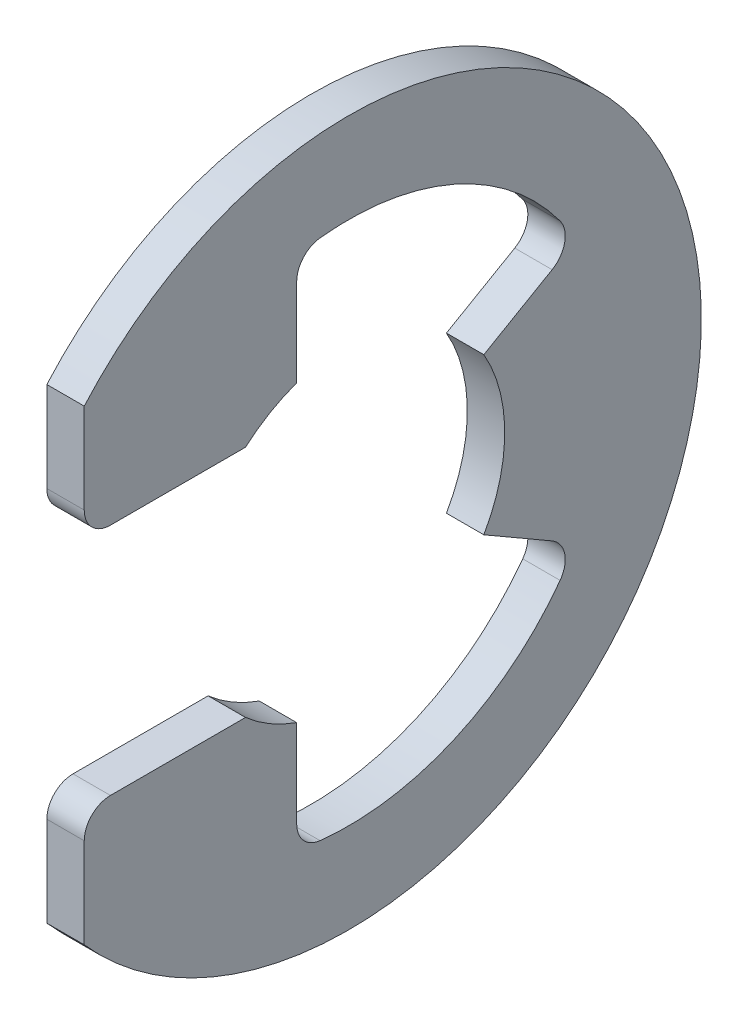
from build123d import *

# Parameters (mm, degrees)
EXTRUDE1_DEPTH = 0.4445
FILLET1_R      = 0.6223


with BuildPart() as part:
    # Sketch1 → Extrude1 (new body, symmetric)
    with BuildSketch(Plane(origin=(0, 0, 0), x_dir=(0, 0, -1), z_dir=(1, 0, 0))):
        with BuildLine():
            Line((-2.45287604, 2.7813), (-6.2865, 2.7813))
            Line((-6.2865, 2.7813), (-6.2865, 5.544171872))
            ThreePointArc((-6.2865, 5.544171872), (8.382, 0), (-6.2865, -5.544171872))
            Line((-6.2865, -5.544171872), (-6.2865, -2.7813))
            Line((-6.2865, -2.7813), (-2.45287604, -2.7813))
            ThreePointArc((-2.45287604, -2.7813), (-1.878831673, -3.197220997), (-1.236133333, -3.49631305))
            Line((-1.236133333, -3.49631305), (-1.236133333, -6.116547306))
            ThreePointArc((-1.236133333, -6.116547306), (2.566674294, -5.687913469), (5.404177312, -3.120103226))
            Line((5.404177312, -3.120103226), (3.211568607, -1.8542))
            ThreePointArc((3.211568607, -1.8542), (3.7084, 0), (3.211568607, 1.8542))
            Line((3.211568607, 1.8542), (5.404177312, 3.120103226))
            ThreePointArc((5.404177312, 3.120103226), (2.566674294, 5.687913469), (-1.236133333, 6.116547306))
            Line((-1.236133333, 6.116547306), (-1.236133333, 3.49631305))
            ThreePointArc((-1.236133333, 3.49631305), (-1.878831673, 3.197220997), (-2.45287604, 2.7813))
        make_face()
    extrude(amount=EXTRUDE1_DEPTH, both=True)

    # Fillet1
    fillet1_edges = [part.edges().sort_by_distance(p)[0] for p in [
        (0, -2.7813, 6.2865),
        (0, -6.116547306, 1.236133333),
        (0, -3.120103226, -5.404177312),
        (0, 3.120103226, -5.404177312),
        (0, 6.116547306, 1.236133333),
        (0, 2.7813, 6.2865),
    ]]
    fillet(fillet1_edges, radius=FILLET1_R)


solid = part.part
